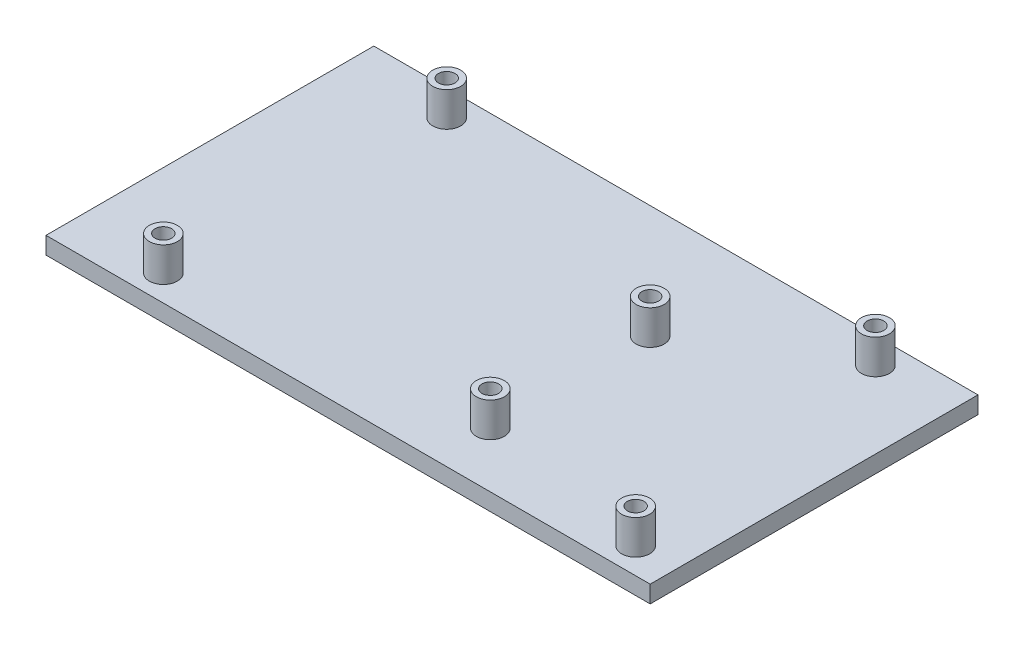
from build123d import *

# Parameters (mm, degrees)
SKETCH1_W           = 105.6
SKETCH1_H           = 57.3
BOSS_EXTRUDE1_DEPTH = 3
SKETCH1_4_R         = 2.45
SKETCH1_4_R_2       = 1.45
BOSS_EXTRUDE2_DEPTH = 6


with BuildPart() as part:
    # Sketch1 → Boss-Extrude1 (new body)
    with BuildSketch(Plane(origin=(0, 0, 0), x_dir=(1, 0, 0), z_dir=(0, 1, 0))):
        with Locations((50.8, 26.65)):
            Rectangle(SKETCH1_W, SKETCH1_H)
    extrude(amount=-BOSS_EXTRUDE1_DEPTH)

    # Sketch1_4 → Boss-Extrude2 (add)
    with BuildSketch(Plane(origin=(0, 0, 0), x_dir=(1, 0, 0), z_dir=(0, 1, 0))):
        with Locations(Location((13.97, 2.54, 0), (0, 0, 270))):  # turned: the seam where the file's is
            Circle(SKETCH1_4_R)
        with Locations(Location((13.97, 2.54, 0), (0, 0, 270))):  # turned: the seam where the file's is
            Circle(SKETCH1_4_R_2, mode=Mode.SUBTRACT)
        with Locations(Location((15.24, 50.8, 0), (0, 0, 270))):  # turned: the seam where the file's is
            Circle(SKETCH1_4_R)
        with Locations(Location((15.24, 50.8, 0), (0, 0, 270))):  # turned: the seam where the file's is
            Circle(SKETCH1_4_R_2, mode=Mode.SUBTRACT)
        with Locations(Location((66.04, 35.56, 0), (0, 0, 270))):  # turned: the seam where the file's is
            Circle(SKETCH1_4_R)
        with Locations(Location((66.04, 35.56, 0), (0, 0, 270))):  # turned: the seam where the file's is
            Circle(SKETCH1_4_R_2, mode=Mode.SUBTRACT)
        with Locations(Location((66.04, 7.62, 0), (0, 0, 270))):  # turned: the seam where the file's is
            Circle(SKETCH1_4_R)
        with Locations(Location((66.04, 7.62, 0), (0, 0, 270))):  # turned: the seam where the file's is
            Circle(SKETCH1_4_R_2, mode=Mode.SUBTRACT)
        with Locations(Location((96.52, 2.54, 0), (0, 0, 270))):  # turned: the seam where the file's is
            Circle(SKETCH1_4_R)
        with Locations(Location((96.52, 2.54, 0), (0, 0, 270))):  # turned: the seam where the file's is
            Circle(SKETCH1_4_R_2, mode=Mode.SUBTRACT)
        with Locations(Location((90.17, 50.8, 0), (0, 0, 270))):  # turned: the seam where the file's is
            Circle(SKETCH1_4_R)
        with Locations(Location((90.17, 50.8, 0), (0, 0, 270))):  # turned: the seam where the file's is
            Circle(SKETCH1_4_R_2, mode=Mode.SUBTRACT)
    extrude(amount=BOSS_EXTRUDE2_DEPTH)


solid = part.part
